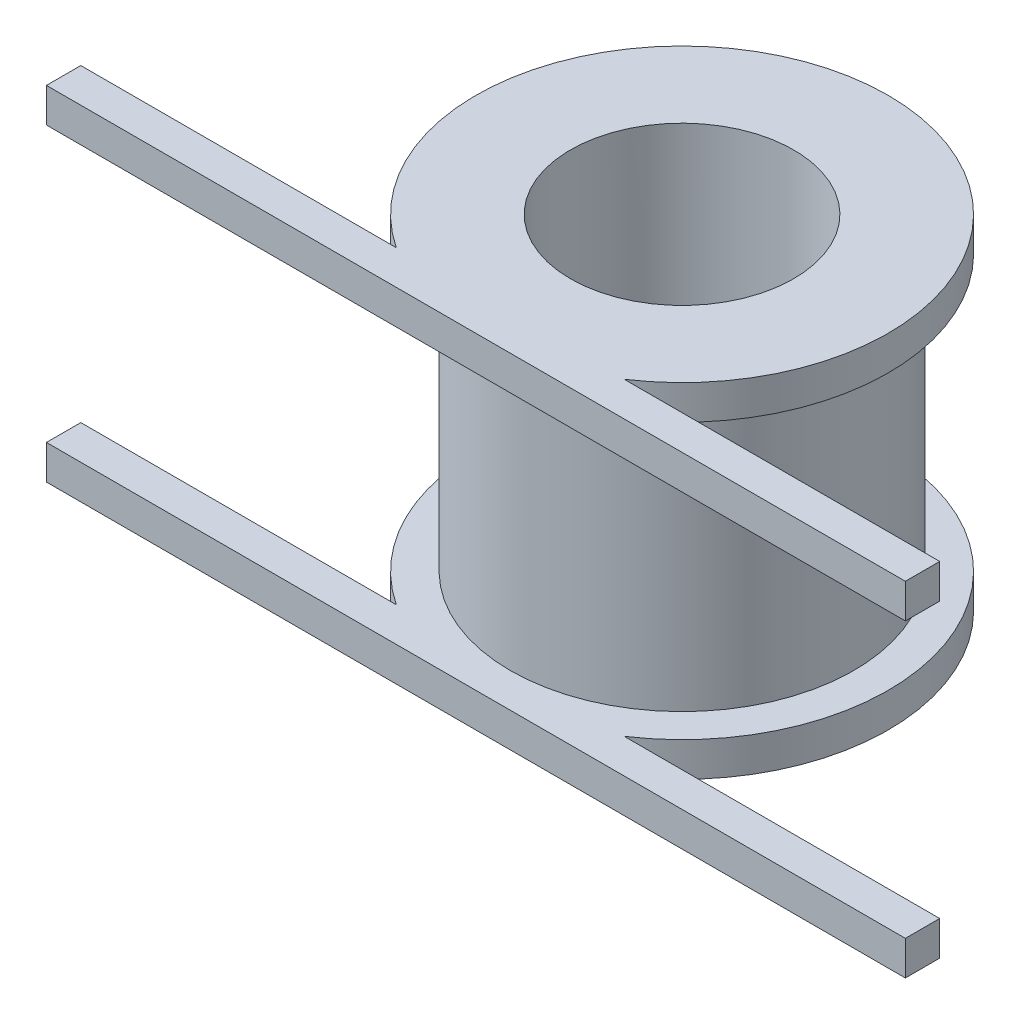
from build123d import *

# Parameters (mm, degrees)
SKETCH_1_R          = 10
SKETCH_1_R_2        = 6.5
EXTRUDE_1_DEPTH     = 20
SKETCH_1_W          = 50
SKETCH_1_H          = 2
EXTRUDE_1_2_DEPTH   = 20
SKETCH_2_W          = 2
SKETCH_2_H          = 16
CUT_EXTRUDE_2_DEPTH = 50
SKETCH_3_R          = 12
EXTRUDE_2_DEPTH     = 2
SKETCH_5_R          = 12
SKETCH_5_R_2        = 6.5
EXTRUDE_3_DEPTH     = 2
SKETCH_4_R          = 6.5
CUT_EXTRUDE_4_DEPTH = 2


with BuildPart() as part:
    # 草图1 → 凸台-拉伸1 (new body)
    with BuildSketch(Plane(origin=(0, 0, 0), x_dir=(1, 0, 0), z_dir=(0, 1, 0))):
        Circle(SKETCH_1_R)
        Circle(SKETCH_1_R_2, mode=Mode.SUBTRACT)
    extrude(amount=EXTRUDE_1_DEPTH)



with BuildPart() as body_2:
    # 草图1 → Extrude 1 2 (new body)
    with BuildSketch(Plane(origin=(0, 0, 0), x_dir=(1, 0, 0), z_dir=(0, 1, 0))):
        with Locations((0, -11)):
            Rectangle(SKETCH_1_W, SKETCH_1_H)
    extrude(amount=EXTRUDE_1_2_DEPTH)

    # 草图2 → 切除-拉伸2 (cut)
    with BuildSketch(Plane.ZY.offset(25)):
        with Locations((11, 10)):
            Rectangle(SKETCH_2_W, SKETCH_2_H)
    extrude(amount=-CUT_EXTRUDE_2_DEPTH, mode=Mode.SUBTRACT)


with BuildPart() as part_1:
    add(part.part)

    add(body_2.part)  # 凸台-拉伸2 merges body 2
    # 草图3 → 凸台-拉伸2 (add)
    with BuildSketch(Plane(origin=(0, 0, 0), x_dir=(1, 0, 0), z_dir=(0, 1, 0))):
        Circle(SKETCH_3_R)
    extrude(amount=EXTRUDE_2_DEPTH)

    # 草图5 → 凸台-拉伸3 (add)
    with BuildSketch(Plane(origin=(0, 20, 0), x_dir=(1, 0, 0), z_dir=(0, 1, 0))):
        Circle(SKETCH_5_R)
        Circle(SKETCH_5_R_2, mode=Mode.SUBTRACT)
    extrude(amount=-EXTRUDE_3_DEPTH)

    # 草图4 → 切除-拉伸4 (cut)
    with BuildSketch(Plane.XZ):
        Circle(SKETCH_4_R)
    extrude(amount=-CUT_EXTRUDE_4_DEPTH, mode=Mode.SUBTRACT)


solid = part_1.part
